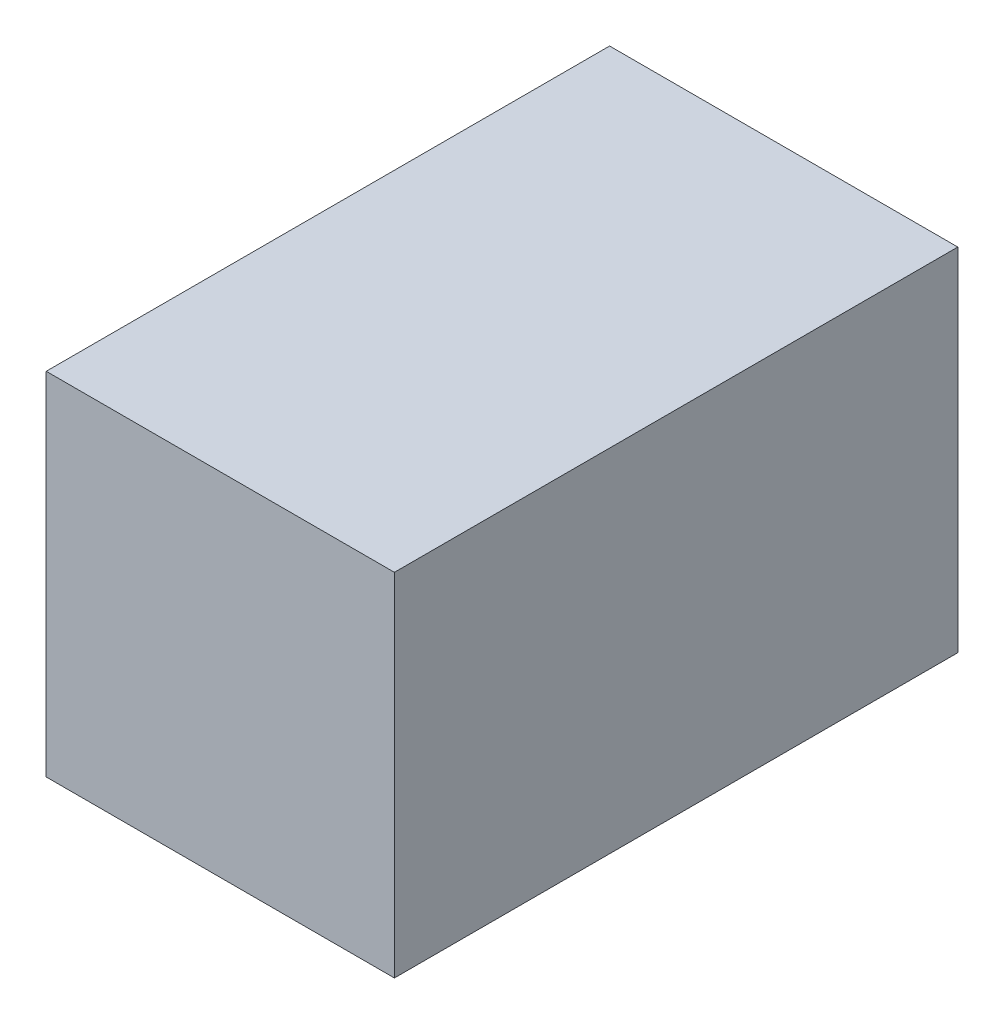
from build123d import *

# Parameters (mm, degrees)
SKETCH1_W           = 49.1109
SKETCH1_H           = 79.4639
BOSS_EXTRUDE1_DEPTH = 49.5554


with BuildPart() as part:
    # Sketch1 → Boss-Extrude1 (new body)
    with BuildSketch(Plane(origin=(0, 0, 0), x_dir=(1, 0, 0), z_dir=(0, 1, 0))):
        with Locations((24.55545, 39.73195)):
            Rectangle(SKETCH1_W, SKETCH1_H)
    extrude(amount=BOSS_EXTRUDE1_DEPTH)


solid = part.part
